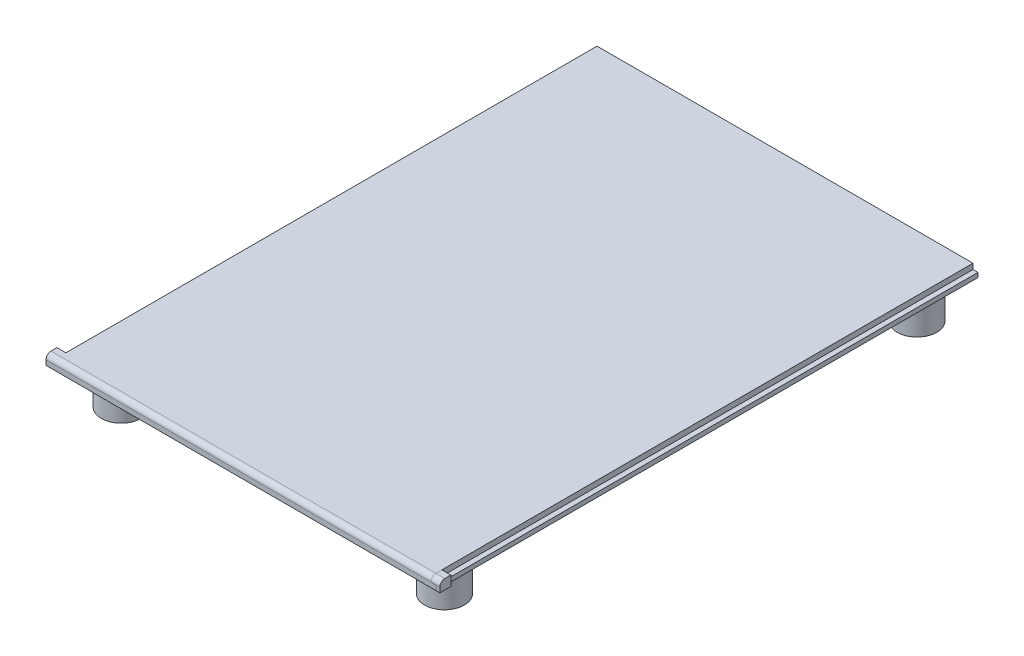
from build123d import *

# Parameters (mm, degrees)
SKETCH1_W           = 77.6
SKETCH1_H           = 109
BOSS_EXTRUDE1_DEPTH = 2
SKETCH2_W           = 1
SKETCH2_H           = 109
CUT_EXTRUDE1_DEPTH  = 1.1
SKETCH3_R           = 4
SKETCH3_R_2         = 1.5
BOSS_EXTRUDE2_DEPTH = 10
SKETCH4_W           = 1.8
SKETCH4_H           = 2.2
BOSS_EXTRUDE3_DEPTH = 2
SKETCH5_W           = 1.8
SKETCH5_H           = 2.2
BOSS_EXTRUDE4_DEPTH = 2
FILLET1_R           = 1
FILLET2_R           = 1


with BuildPart() as part:
    # Sketch1 → Boss-Extrude1 (new body)
    with BuildSketch(Plane(origin=(0, 0, 0), x_dir=(1, 0, 0), z_dir=(0, 1, 0))):
        with Locations((38.8, 54.5)):
            Rectangle(SKETCH1_W, SKETCH1_H)
    extrude(amount=BOSS_EXTRUDE1_DEPTH)

    # Sketch2 → Cut-Extrude1 (cut)
    with BuildSketch(Plane(origin=(0, 2, 0), x_dir=(1, 0, 0), z_dir=(0, 1, 0))):
        with Locations((77.1, 54.5)):
            Rectangle(SKETCH2_W, SKETCH2_H)
        with Locations((0.5, 54.5)):
            Rectangle(SKETCH2_W, SKETCH2_H)
    extrude(amount=-CUT_EXTRUDE1_DEPTH, mode=Mode.SUBTRACT)

    # Sketch3 → Boss-Extrude2 (add)
    with BuildSketch(Plane(origin=(0, 2, 0), x_dir=(1, 0, 0), z_dir=(0, 1, 0))):
        with Locations((6, 103.319481559)):
            Circle(SKETCH3_R)
        with Locations((6, 103.319481559)):
            Circle(SKETCH3_R_2, mode=Mode.SUBTRACT)
        with Locations((6, 8.319481559)):
            Circle(SKETCH3_R)
        with Locations((6, 8.319481559)):
            Circle(SKETCH3_R_2, mode=Mode.SUBTRACT)
        with Locations((71, 8.319481559)):
            Circle(SKETCH3_R)
        with Locations((71, 8.319481559)):
            Circle(SKETCH3_R_2, mode=Mode.SUBTRACT)
        with Locations((71, 103.319481559)):
            Circle(SKETCH3_R)
        with Locations((71, 103.319481559)):
            Circle(SKETCH3_R_2, mode=Mode.SUBTRACT)
    extrude(amount=-BOSS_EXTRUDE2_DEPTH)

    # Sketch4 → Boss-Extrude3 (add)
    with BuildSketch(Plane(origin=(0, 2, 0), x_dir=(1, 0, 0), z_dir=(0, 1, 0))):
        with Locations((0.1, 1.1)):
            Rectangle(SKETCH4_W, SKETCH4_H)
    extrude(amount=-BOSS_EXTRUDE3_DEPTH)

    # Fillet1
    fillet1_edges = [part.edges().sort_by_distance(p)[0] for p in [
        (37.9, 2, 0),
    ]]
    fillet(fillet1_edges, radius=FILLET1_R)


with BuildPart() as body_2:
    # Sketch5 → Boss-Extrude4 (new body)
    with BuildSketch(Plane(origin=(0, 2, 0), x_dir=(1, 0, 0), z_dir=(0, 1, 0))):
        with Locations((77.5, 1.1)):
            Rectangle(SKETCH5_W, SKETCH5_H)
    extrude(amount=-BOSS_EXTRUDE4_DEPTH)

    # Fillet2
    fillet2_edges = [body_2.edges().sort_by_distance(p)[0] for p in [
        (77.5, 2, 0),
    ]]
    fillet(fillet2_edges, radius=FILLET2_R)


solid = Compound([part.part, body_2.part])
